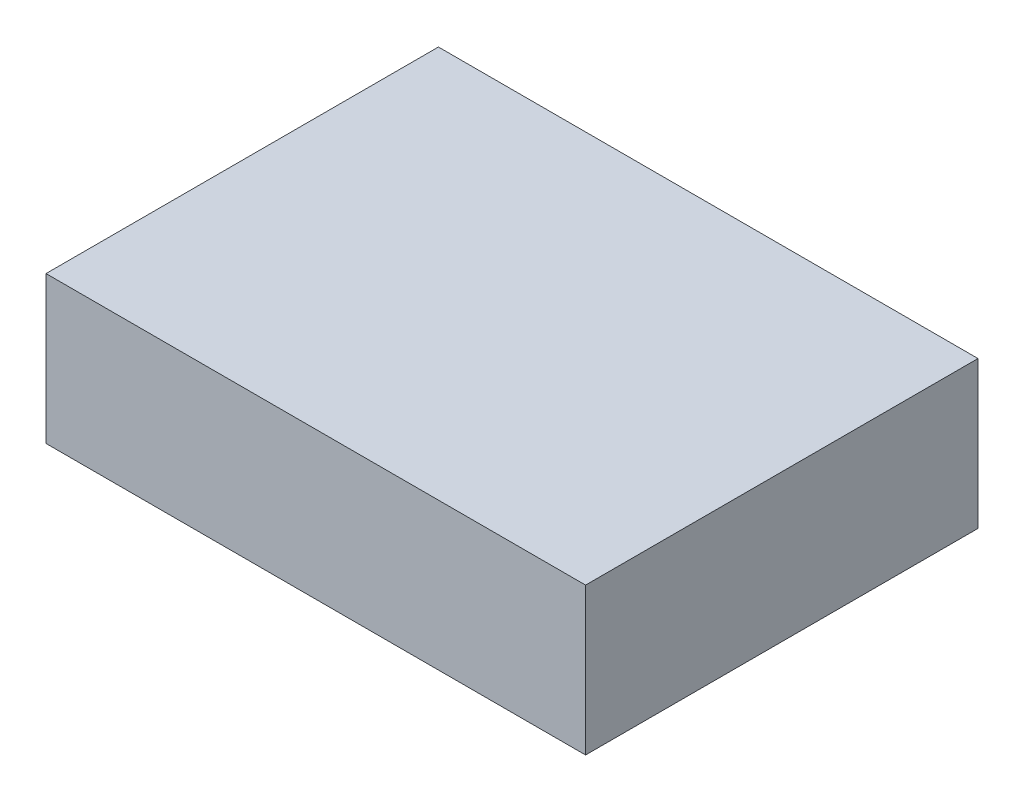
from build123d import *

# Parameters (mm, degrees)
SKETCH1_W                    = 55
SKETCH1_H                    = 40
BOSS_EXTRUDE1_DEPTH          = 15
M1_2X0_25_TAPPED_HOLE1_D     = 0.95
M1_2X0_25_TAPPED_HOLE1_DEPTH = 8.5
M1_2X0_25_TAPPED_HOLE1_TIP   = 0.285408794


with BuildPart() as part:
    # Sketch1 → Boss-Extrude1 (new body)
    with BuildSketch(Plane(origin=(0, 0, 0), x_dir=(1, 0, 0), z_dir=(0, 1, 0))):
        Rectangle(SKETCH1_W, SKETCH1_H)
    extrude(amount=BOSS_EXTRUDE1_DEPTH)

    # M1.2x0.25 Tapped Hole1
    with Locations(Plane(origin=(0, 0, 0), x_dir=(-1, 0, 0), z_dir=(0, -1, 0))):
        with Locations((-23.5, -16), (23.5, 16)):
            Hole(M1_2X0_25_TAPPED_HOLE1_D / 2, depth=M1_2X0_25_TAPPED_HOLE1_DEPTH)
            with Locations((0, 0, -(M1_2X0_25_TAPPED_HOLE1_DEPTH + M1_2X0_25_TAPPED_HOLE1_TIP / 2))):  # 118° drill point
                Cone(0, M1_2X0_25_TAPPED_HOLE1_D / 2, M1_2X0_25_TAPPED_HOLE1_TIP, mode=Mode.SUBTRACT)


solid = part.part
